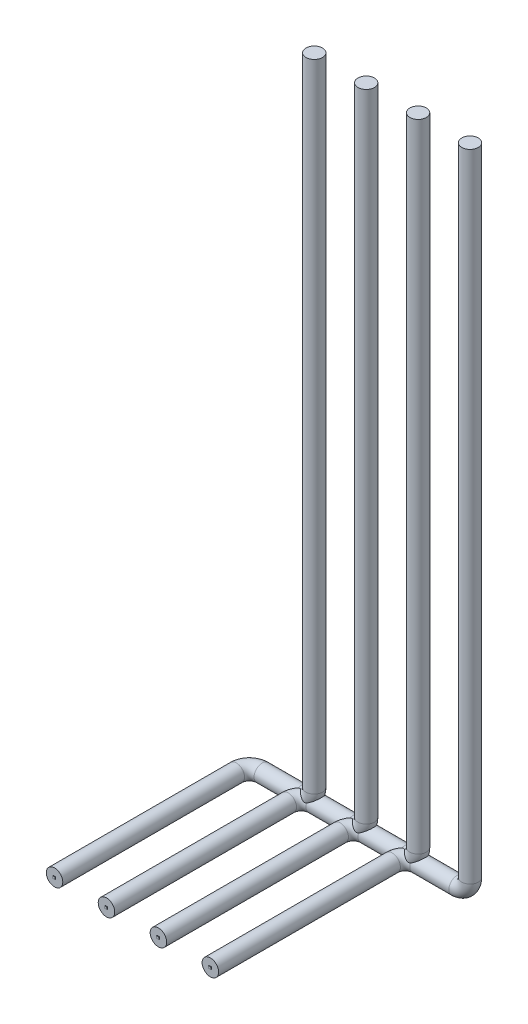
from build123d import *

# Parameters (mm, degrees)
CROQUIS2_R              = 12.7
CROQUIS3_W              = 3.623485192
CROQUIS3_H              = 3.312562446
SALIENTE_EXTRUIR1_DEPTH = 1
MATRIZL1_COUNT          = 4
MATRIZL1_PITCH          = 80


with BuildPart() as part:
    # Barrer1: sweep along a curve in space
    with BuildLine() as barrer1_path:
        Line((0, 0, 0), (0, 0, -280))
        ThreePointArc((0, 0, -280), (5.857864376, 0, -294.142135624), (20, 0, -300))
        Line((20, 0, -300), (80, 0, -300))
        ThreePointArc((80, 0, -300), (94.142135624, 5.857864376, -300), (100, 20, -300))
        Line((100, 20, -300), (100, 1000, -300))
    # Croquis2 → Barrer1 (sweep)
    with BuildSketch(Plane.XY):
        Circle(CROQUIS2_R)
    sweep(path=barrer1_path.line)

    # Croquis3 → Saliente-Extruir1 (add)
    with BuildSketch(Plane.XY):
        Rectangle(CROQUIS3_W, CROQUIS3_H)
    extrude(amount=SALIENTE_EXTRUIR1_DEPTH)


with BuildPart() as matrizl1_1:
    # MatrizL1: pattern copy
    add(part.part.moved(Location(Vector(1, 0, 0) * (1 * MATRIZL1_PITCH))))


with BuildPart() as matrizl1_2:
    # MatrizL1: pattern copy
    add(part.part.moved(Location(Vector(1, 0, 0) * (2 * MATRIZL1_PITCH))))


with BuildPart() as matrizl1_3:
    # MatrizL1: pattern copy
    add(part.part.moved(Location(Vector(1, 0, 0) * (3 * MATRIZL1_PITCH))))


solid = Compound([part.part, matrizl1_1.part, matrizl1_2.part, matrizl1_3.part])
